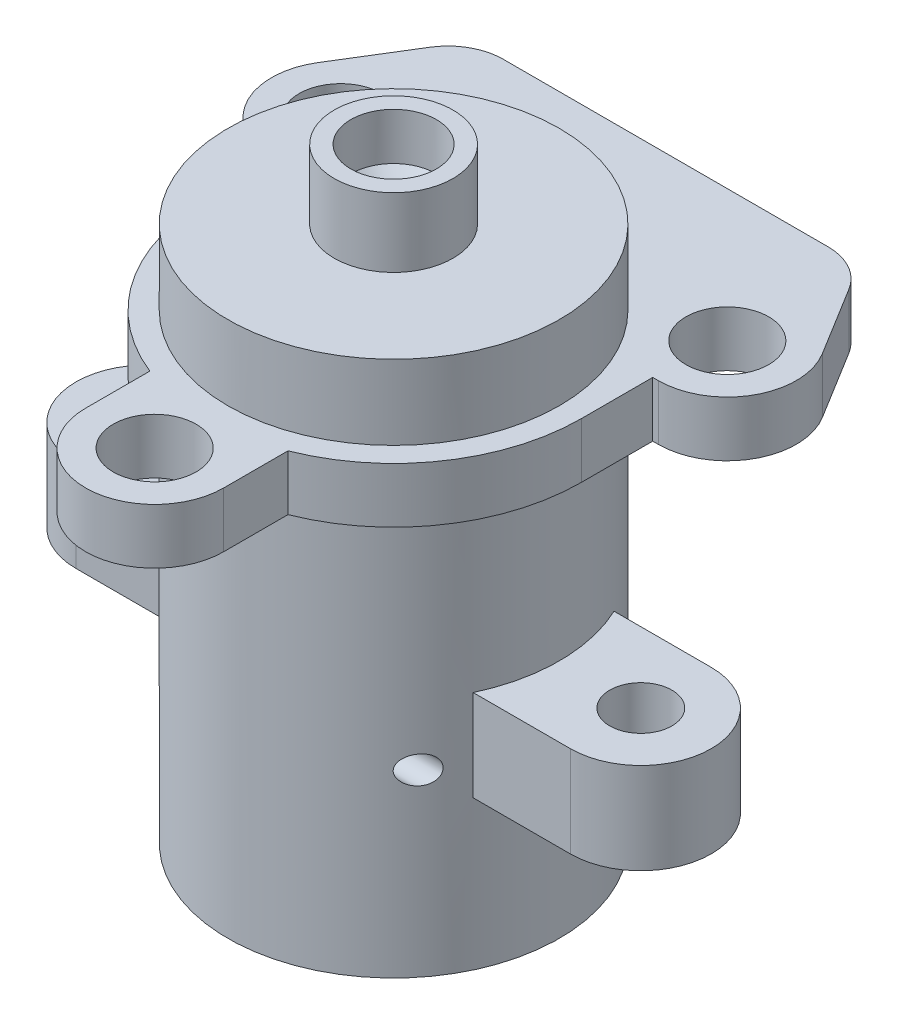
from build123d import *

# Parameters (mm, degrees)
SKETCH2_R               = 2.15
EXTRUDE1_DEPTH          = 2.5
SKETCH3_R               = 1.55
CUT_EXTRUDE1_DEPTH      = 2.5
SKETCH4_R               = 0.75
CUT_EXTRUDE2_DEPTH      = 22.9
SKETCH6_R               = 6
SKETCH6_R_2             = 1.5
EXTRUDE2_DEPTH          = 2
FILLET1_R               = 2
SKETCH7_R               = 1.125
EXTRUDE3_DEPTH          = 3.3
SKETCH9_R               = 0.5
CUT_EXTRUDE3_DEPTH      = 12.5
CUT_EXTRUDE3_DEPTH_BACK = 12.5


with BuildPart() as part:
    # Sketch1 → Revolve1 (revolve)
    with BuildSketch(Plane.XY, mode=Mode.PRIVATE) as revolve1_sk:
        Polygon((0, 0), (6, 0), (6, -19.4), (5, -19.4), (5, -1.2), (0, -1.2), align=None)
    revolve(revolve1_sk.sketch.rotate(Axis((0, -1001.336186186, 0), (0, 1, 0)), 90), axis=Axis((0, -1001.336186186, 0), (0, 1, 0)))  # turned: the seam where the file's is

    # Sketch2 → Extrude1 (add)
    with BuildSketch(Plane(origin=(0, 0, 0), x_dir=(1, 0, 0), z_dir=(0, 1, 0))):
        with Locations(Location((0, 0, 0), (0, 0, 270))):  # turned: the seam where the file's is
            Circle(SKETCH2_R)
    extrude(amount=EXTRUDE1_DEPTH)

    # Sketch3 → Cut-Extrude1 (cut)
    with BuildSketch(Plane(origin=(0, 2.5, 0), x_dir=(1, 0, 0), z_dir=(0, 1, 0))):
        with Locations(Location((0, 0, 0), (0, 0, 270))):  # turned: the seam where the file's is
            Circle(SKETCH3_R)
    extrude(amount=-CUT_EXTRUDE1_DEPTH, mode=Mode.SUBTRACT)

    # Sketch4 → Cut-Extrude2 (cut, through all)
    with BuildSketch(Plane(origin=(0, 2.5, 0), x_dir=(1, 0, 0), z_dir=(0, 1, 0))):
        with Locations(Location((0, 0, 0), (0, 0, 270))):  # turned: the seam where the file's is
            Circle(SKETCH4_R)
    extrude(amount=-CUT_EXTRUDE2_DEPTH, mode=Mode.SUBTRACT)

    # Sketch6 → Extrude2 (add)
    with BuildSketch(Plane(origin=(0, -2.7, 0), x_dir=(-1, 0, 0), z_dir=(0, 1, 0))):
        with BuildLine():
            Line((-6.8, 0), (-6.8, -2.581584399))
            Line((-6.8, -2.581584399), (-7, -2.581584399))
            ThreePointArc((-7, -2.581584399), (-9.182518013, -3.862316124), (-9.128859977, -6.392292299))
            Line((-9.128859977, -6.392292299), (-7, -9.85))
            Line((-7, -9.85), (7, -9.85))
            Line((7, -9.85), (9.128859977, -6.392292299))
            ThreePointArc((9.128859977, -6.392292299), (9.182518013, -3.862316124), (7, -2.581584399))
            Line((7, -2.581584399), (6.8, -2.581584399))
            Line((6.8, -2.581584399), (6.8, 0))
            ThreePointArc((6.8, 0), (5.623166368, 3.823610859), (2.5, 6.323764702))
            Line((2.5, 6.323764702), (2.5, 8.65))
            ThreePointArc((2.5, 8.65), (0, 11.15), (-2.5, 8.65))
            Line((-2.5, 8.65), (-2.5, 6.323764702))
            ThreePointArc((-2.5, 6.323764702), (-5.623166368, 3.823610859), (-6.8, 0))
        make_face()
        with Locations(Location((0, 0, 0), (0, 0, 270))):  # turned: the seam where the file's is
            Circle(SKETCH6_R, mode=Mode.SUBTRACT)
        with Locations(Location((0, 8.65, 0), (0, 0, 90))):  # turned: the seam where the file's is
            Circle(SKETCH6_R_2, mode=Mode.SUBTRACT)
        with Locations(Location((7, -5.081584399, 0), (0, 0, 90))):  # turned: the seam where the file's is
            Circle(SKETCH6_R_2, mode=Mode.SUBTRACT)
        with Locations(Location((-7, -5.081584399, 0), (0, 0, 90))):  # turned: the seam where the file's is
            Circle(SKETCH6_R_2, mode=Mode.SUBTRACT)
    extrude(amount=-EXTRUDE2_DEPTH)

    # Fillet1
    fillet1_edges = [part.edges().sort_by_distance(p)[0] for p in [
        (-7, -3.7, -9.85),
        (7, -3.7, -9.85),
    ]]
    fillet(fillet1_edges, radius=FILLET1_R)

    # Sketch7 → Extrude3 (add)
    with BuildSketch(Plane(origin=(0, -14, 0), x_dir=(-1, 0, 0), z_dir=(0, 1, 0))):
        with BuildLine():
            Line((-8.95, 2.55), (-5.431160097, 2.55))
            ThreePointArc((-5.431160097, 2.55), (-6, 0), (-5.431160097, -2.55))
            Line((-5.431160097, -2.55), (-8.95, -2.55))
            ThreePointArc((-8.95, -2.55), (-11.5, 0), (-8.95, 2.55))
        make_face()
        with Locations(Location((-8.95, 0, 0), (0, 0, 90))):  # turned: the seam where the file's is
            Circle(SKETCH7_R, mode=Mode.SUBTRACT)
        with BuildLine():
            Line((5.431160097, 2.55), (8.95, 2.55))
            ThreePointArc((8.95, 2.55), (11.5, 0), (8.95, -2.55))
            Line((8.95, -2.55), (5.431160097, -2.55))
            ThreePointArc((5.431160097, -2.55), (6, 0), (5.431160097, 2.55))
        make_face()
        with Locations(Location((8.95, 0, 0), (0, 0, 90))):  # turned: the seam where the file's is
            Circle(SKETCH7_R, mode=Mode.SUBTRACT)
    extrude(amount=EXTRUDE3_DEPTH)

    # Sketch8 → Revolve2 (revolve)
    with BuildSketch(Plane.XY, mode=Mode.PRIVATE) as revolve2_sk:
        Polygon((1.55, 0), (0.75, 0), (1.55, 0.8), align=None)
    revolve(revolve2_sk.sketch.rotate(Axis((0, -999.622226969, 0), (0, 1, 0)), 90), axis=Axis((0, -999.622226969, 0), (0, 1, 0)))  # turned: the seam where the file's is

    # Sketch9 → Cut-Extrude3 (cut, two sides)
    with BuildSketch(Plane(origin=(0, 0, 0), x_dir=(0, 0, -1), z_dir=(1, 0, 0))) as cut_extrude3_sk:
        with Locations((3.75, -12.9)):
            Circle(SKETCH9_R)
        with Locations((-3.75, -12.9)):
            Circle(SKETCH9_R)
    extrude(amount=CUT_EXTRUDE3_DEPTH, mode=Mode.SUBTRACT)
    extrude(cut_extrude3_sk.sketch, amount=-CUT_EXTRUDE3_DEPTH_BACK, mode=Mode.SUBTRACT)


solid = part.part
